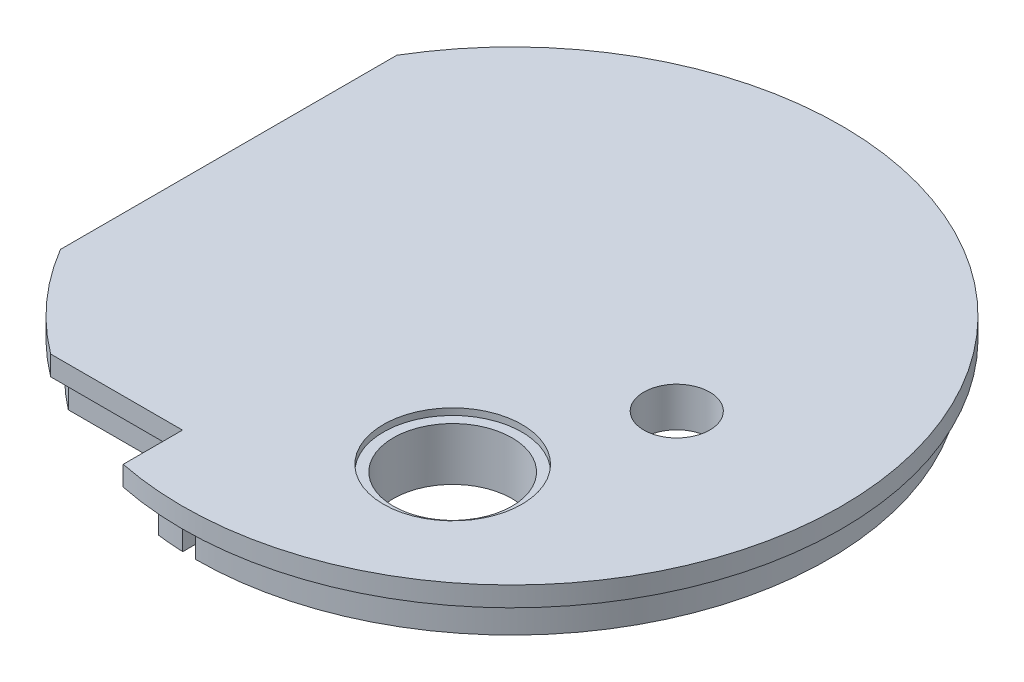
from build123d import *

# Parameters (mm, degrees)
BOSS_EXTRUDE1_DEPTH = 3
BOSS_EXTRUDE2_DEPTH = 5
SKETCH3_R           = 5
SKETCH3_R_2         = 9
CUT_EXTRUDE1_DEPTH  = 3
SKETCH4_R           = 9
SKETCH4_R_2         = 8
BOSS_EXTRUDE3_DEPTH = 3
BOSS_EXTRUDE4_START = 3
SKETCH4_3_R         = 6
SKETCH4_3_R_2       = 5
BOSS_EXTRUDE4_DEPTH = 3
BOSS_EXTRUDE5_START = 6
SKETCH6_R           = 10.5
SKETCH6_R_2         = 9
BOSS_EXTRUDE5_DEPTH = 6
CUT_EXTRUDE2_START  = -1
SKETCH7_R           = 10.5
SKETCH7_R_2         = 9
CUT_EXTRUDE2_DEPTH  = 1


with BuildPart() as part:
    # Sketch1 → Boss-Extrude1 (new body)
    with BuildSketch(Plane(origin=(0, 0, 0), x_dir=(1, 0, 0), z_dir=(0, 1, 0))):
        with BuildLine():
            Line((-43, 25.514701644), (-43, -25.514701644))
            ThreePointArc((-43, -25.514701644), (-37.211637523, -33.396018219), (-30, -40))
            Line((-30, -40), (-10, -40))
            Line((-10, -40), (-10, -48.989794856))
            ThreePointArc((-10, -48.989794856), (45.716299059, 20.248950598), (-43, 25.514701644))
        make_face()
    extrude(amount=BOSS_EXTRUDE1_DEPTH)

    # Sketch2 → Boss-Extrude2 (add)
    with BuildSketch(Plane.XZ):
        with BuildLine():
            Line((-40.978122, 24.995870006), (-40.978122, -24.995870006))
            ThreePointArc((-40.978122, -24.995870006), (-26.914721681, -39.744153744), (-8, -47.328638265))
            Line((-8, -47.328638265), (-8, -45.299006612))
            ThreePointArc((-8, -45.299006612), (-25.702922785, -38.149177715), (-38.978122, -24.427566505))
            Line((-38.978122, -24.427566505), (-38.978122, 24.427566505))
            ThreePointArc((-38.978122, 24.427566505), (-34.298477795, 30.653130687), (-28.635642127, 36))
            Line((-28.635642127, 36), (-8, 36))
            Line((-8, 36), (-8, 38))
            Line((-8, 38), (-29.325756597, 38))
            ThreePointArc((-29.325756597, 38), (-35.748226329, 32.032238672), (-40.978122, 24.995870006))
        make_face()
        with BuildLine():
            Line((-6, 45.607017004), (-6, 47.623523599))
            ThreePointArc((-6, 47.623523599), (-4.003501138, 47.832750064), (-2, 47.958315233))
            Line((-2, 47.958315233), (-2, 45.956501172))
            ThreePointArc((-2, 45.956501172), (-4.00381503, 45.825423786), (-6, 45.607017004))
        make_face()
        with BuildLine():
            Line((-6, -45.607017004), (-6, -47.623523599))
            ThreePointArc((-6, -47.623523599), (-4.003501138, -47.832750064), (-2, -47.958315233))
            Line((-2, -47.958315233), (-2, -45.956501172))
            ThreePointArc((-2, -45.956501172), (-4.00381503, -45.825423786), (-6, -45.607017004))
        make_face()
        with BuildLine():
            Line((0, 46), (0, 48))
            ThreePointArc((0, 48), (48, 0), (0, -48))
            Line((0, -48), (0, -46))
            ThreePointArc((0, -46), (46, 0), (0, 46))
        make_face()
    extrude(amount=BOSS_EXTRUDE2_DEPTH)

    # Sketch3 → Cut-Extrude1 (cut)
    with BuildSketch(Plane.XZ):
        with Locations((25, 0)):
            Circle(SKETCH3_R)
        with Locations((15, 24)):
            Circle(SKETCH3_R_2)
    extrude(amount=-CUT_EXTRUDE1_DEPTH, mode=Mode.SUBTRACT)

    # Sketch4 → Boss-Extrude3 (add)
    with BuildSketch(Plane.XZ):
        with Locations((25, 0)):
            Circle(SKETCH4_R)
        with Locations((25, 0)):
            Circle(SKETCH4_R_2, mode=Mode.SUBTRACT)
    extrude(amount=BOSS_EXTRUDE3_DEPTH)

    # Sketch4_3 → Boss-Extrude4 (add)
    with BuildSketch(Plane.XZ.offset(BOSS_EXTRUDE4_START)):
        with Locations((25, 0)):
            Circle(SKETCH4_3_R)
        with Locations((25, 0)):
            Circle(SKETCH4_3_R_2, mode=Mode.SUBTRACT)
    extrude(amount=-BOSS_EXTRUDE4_DEPTH)

    # Sketch6 → Boss-Extrude5 (add)
    with BuildSketch(Plane.XZ.offset(BOSS_EXTRUDE5_START)):
        with Locations((15, 24)):
            Circle(SKETCH6_R)
        with Locations((15, 24)):
            Circle(SKETCH6_R_2, mode=Mode.SUBTRACT)
    extrude(amount=-BOSS_EXTRUDE5_DEPTH)

    # Sketch7 → Cut-Extrude2 (cut)
    with BuildSketch(Plane(origin=(0, 3, 0), x_dir=(1, 0, 0), z_dir=(0, 1, 0)).offset(CUT_EXTRUDE2_START)):
        with Locations((15, -24)):
            Circle(SKETCH7_R)
        with Locations((15, -24)):
            Circle(SKETCH7_R_2, mode=Mode.SUBTRACT)
    extrude(amount=CUT_EXTRUDE2_DEPTH, mode=Mode.SUBTRACT)


solid = part.part
